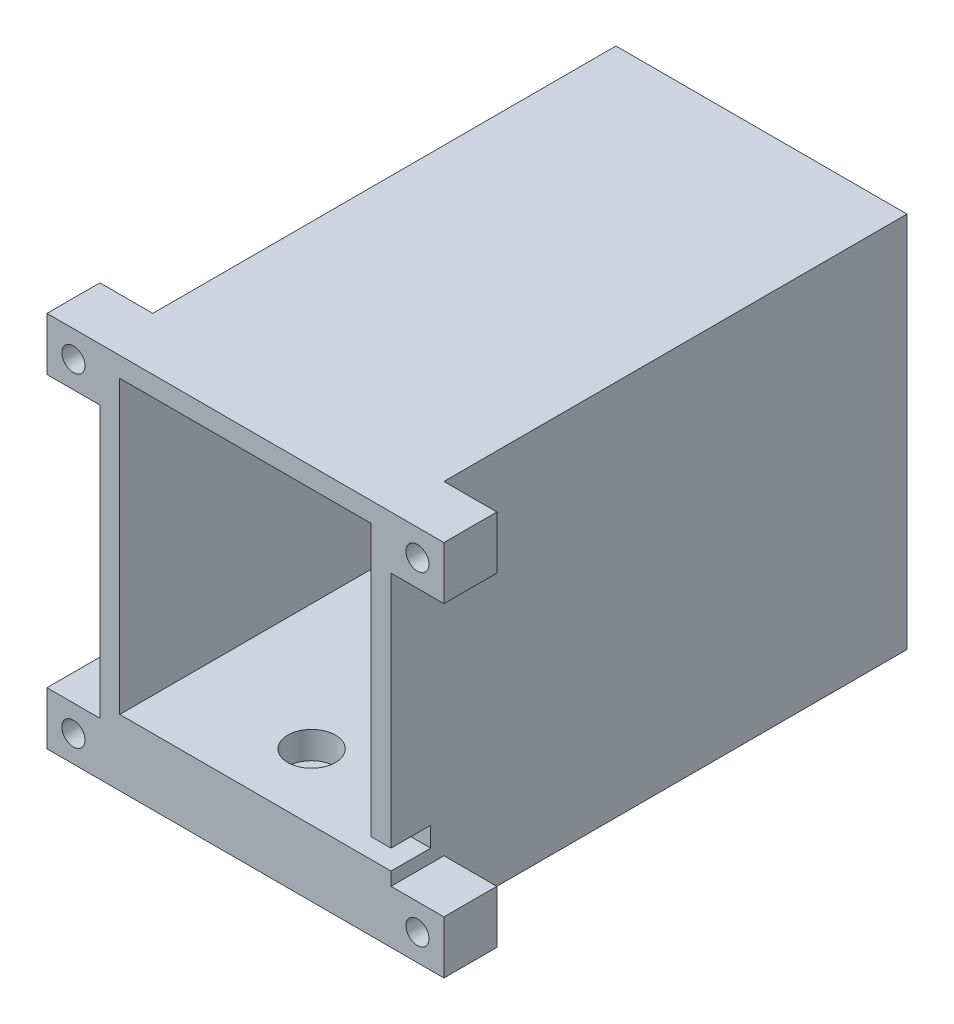
from build123d import *

# Parameters (mm, degrees)
SKETCH_1_W                 = 44
SKETCH_1_H                 = 78
EXTRUDE_1_DEPTH            = 57
SHELL_1_T                  = -3
SHELL_1_THICKNESS_2_FACE_W = 75
SHELL_1_THICKNESS_2_FACE_H = 38
SHELL_1_THICKNESS_2_DEPTH  = 7
SKETCH_3_R                 = 3.6
CUT_EXTRUDE_1_DEPTH        = 4.1
CUT_EXTRUDE_2_REACH        = 66.915
SKETCH_4_R                 = 2.25
SKETCH_5_W                 = 3
SKETCH_5_H                 = 3
CUT_EXTRUDE_3_DEPTH        = 6
SKETCH_6_W                 = 8
SKETCH_6_H                 = 8
SKETCH_6_R                 = 1.75
EXTRUDE_2_DEPTH            = 8
CUT_EXTRUDE_4_DEPTH        = 2.6
CUT_EXTRUDE_5_REACH        = 100.864
SKETCH_8_R                 = 5


with BuildPart() as part:
    # 草圖1 → 填料-伸長1 (new body)
    with BuildSketch(Plane(origin=(0, 0, 0), x_dir=(1, 0, 0), z_dir=(0, 1, 0))):
        Rectangle(SKETCH_1_W, SKETCH_1_H)
    extrude(amount=EXTRUDE_1_DEPTH)

    # 薄殼1
    shell_1_openings = [part.faces().sort_by_distance(p)[0] for p in [
        (0, 28.5, 39),
    ]]
    offset(amount=SHELL_1_T, openings=shell_1_openings, kind=Kind.INTERSECTION)

    # 薄殼1 thickness 2 face (on inner face of the shell) → 薄殼1 thickness 2 (add)
    with BuildSketch(Plane(origin=(0, 3, 1.5), x_dir=(0, 0, -1), z_dir=(0, -1, 0))):
        Rectangle(SHELL_1_THICKNESS_2_FACE_W, SHELL_1_THICKNESS_2_FACE_H)
    extrude(amount=-SHELL_1_THICKNESS_2_DEPTH)

    # 草圖3 → 除料-伸長1 (cut)
    with BuildSketch(Plane(origin=(0, 10, 0), x_dir=(1, 0, 0), z_dir=(0, 1, 0))):
        with Locations(Location((0, 25, 0), (0, 0, 270))):
            Circle(SKETCH_3_R)
        with Locations(Location((0, -29, 0), (0, 0, 270))):
            Circle(SKETCH_3_R)
    extrude(amount=-CUT_EXTRUDE_1_DEPTH, mode=Mode.SUBTRACT)

    # 草圖4 → 除料-伸長2 (cut, up to next)
    with BuildSketch(Plane(origin=(0, 10, 0), x_dir=(1, 0, 0), z_dir=(0, 1, 0)), mode=Mode.PRIVATE) as cut_extrude_2_sk1:
        with Locations(Location((0, 25, 0), (0, 0, 270))):
            Circle(SKETCH_4_R)
    cut_extrude_2_tool1 = extrude(cut_extrude_2_sk1.sketch, amount=-CUT_EXTRUDE_2_REACH, mode=Mode.PRIVATE) & part.part
    # 草圖4 → 除料-伸長2 (cut, up to next)
    with BuildSketch(Plane(origin=(0, 10, 0), x_dir=(1, 0, 0), z_dir=(0, 1, 0)), mode=Mode.PRIVATE) as cut_extrude_2_sk2:
        with Locations(Location((0, -29, 0), (0, 0, 270))):
            Circle(SKETCH_4_R)
    cut_extrude_2_tool2 = extrude(cut_extrude_2_sk2.sketch, amount=-CUT_EXTRUDE_2_REACH, mode=Mode.PRIVATE) & part.part
    add(cut_extrude_2_tool1.solids().sort_by_distance((0, 10, -25))[0], mode=Mode.SUBTRACT)
    add(cut_extrude_2_tool2.solids().sort_by_distance((0, 10, 29))[0], mode=Mode.SUBTRACT)

    # 草圖5 → 除料-伸長3 (cut)
    with BuildSketch(Plane.XY.offset(39)):
        with Locations((20.5, 11.5)):
            Rectangle(SKETCH_5_W, SKETCH_5_H)
    extrude(amount=-CUT_EXTRUDE_3_DEPTH, mode=Mode.SUBTRACT)

    # 草圖6 → 填料-伸長2 (add)
    with BuildSketch(Plane.XY.offset(39)):
        with Locations((-26, 53)):
            Rectangle(SKETCH_6_W, SKETCH_6_H)
        with Locations((-26, 53)):
            Circle(SKETCH_6_R, mode=Mode.SUBTRACT)
        with Locations((-26, 4)):
            Rectangle(SKETCH_6_W, SKETCH_6_H)
        with Locations((-26, 4)):
            Circle(SKETCH_6_R, mode=Mode.SUBTRACT)
        with Locations((26, 4)):
            Rectangle(SKETCH_6_W, SKETCH_6_H)
        with Locations(Location((26, 4, 0), (0, 0, 180))):
            Circle(SKETCH_6_R, mode=Mode.SUBTRACT)
        with Locations((26, 53)):
            Rectangle(SKETCH_6_W, SKETCH_6_H)
        with Locations(Location((26, 53, 0), (0, 0, 180))):
            Circle(SKETCH_6_R, mode=Mode.SUBTRACT)
    extrude(amount=-EXTRUDE_2_DEPTH)

    # 草圖7 → 除料-伸長4 (cut)
    with BuildSketch(Plane(origin=(0, 0, 31), x_dir=(-1, 0, 0), z_dir=(0, 0, -1))):
        Polygon((-22.824573519, 53), (-24.41228676, 55.75), (-27.58771324, 55.75), (-29.175426481, 53), (-27.58771324, 50.25), (-24.41228676, 50.25), align=None)
        Polygon((-22.824573519, 4), (-24.41228676, 6.75), (-27.58771324, 6.75), (-29.175426481, 4), (-27.58771324, 1.25), (-24.41228676, 1.25), align=None)
        Polygon((24.41228676, 1.25), (22.824573519, 4), (24.41228676, 6.75), (27.58771324, 6.75), (29.175426481, 4), (27.58771324, 1.25), align=None)
        Polygon((24.41228676, 50.25), (22.824573519, 53), (24.41228676, 55.75), (27.58771324, 55.75), (29.175426481, 53), (27.58771324, 50.25), align=None)
    extrude(amount=-CUT_EXTRUDE_4_DEPTH, mode=Mode.SUBTRACT)

    # 草圖8 → 除料-伸長5 (cut, up to next)
    with BuildSketch(Plane.XY.offset(-36), mode=Mode.PRIVATE) as cut_extrude_5_sk1:
        with Locations((0, 30)):
            Circle(SKETCH_8_R)
    cut_extrude_5_tool1 = extrude(cut_extrude_5_sk1.sketch, amount=-CUT_EXTRUDE_5_REACH, mode=Mode.PRIVATE) & part.part
    add(cut_extrude_5_tool1.solids().sort_by_distance((0, 30, -36))[0], mode=Mode.SUBTRACT)


solid = part.part
